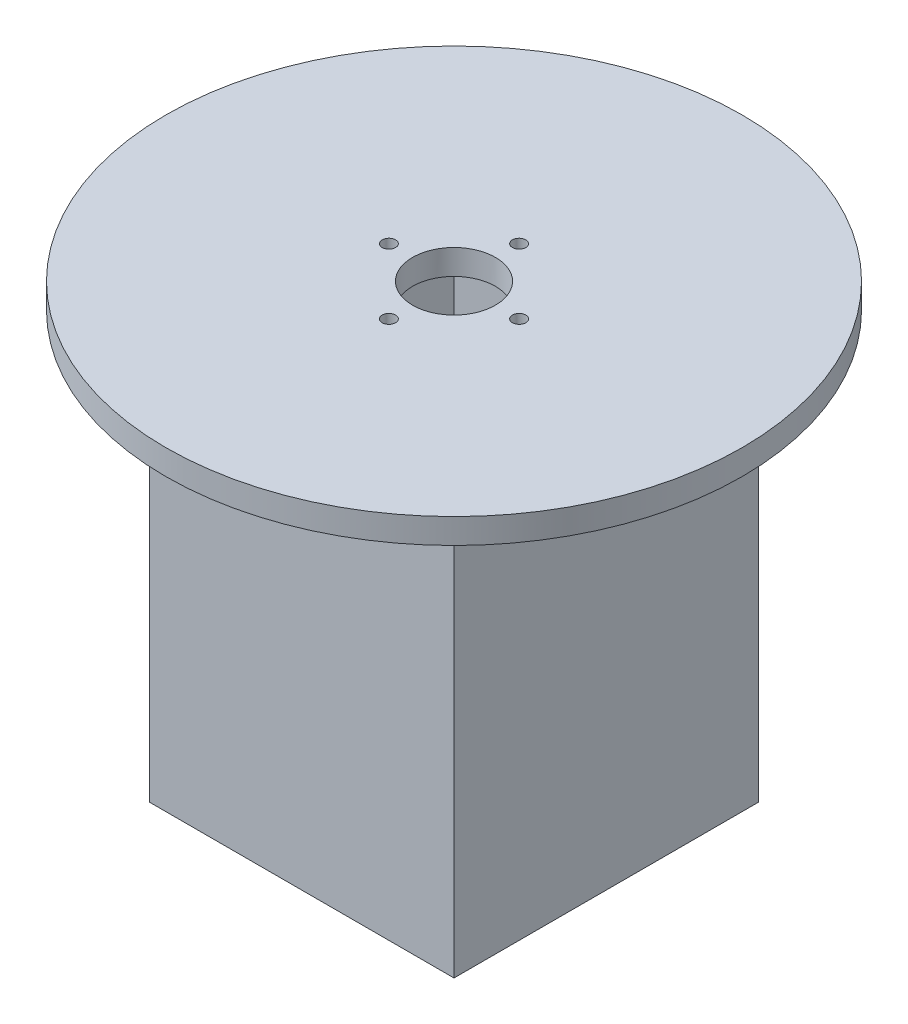
from build123d import *

# Parameters (mm, degrees)
SKETCH1_W           = 77.2
SKETCH1_H           = 114.3
BOSS_EXTRUDE1_DEPTH = 77.2
SKETCH2_W           = 70.58
SKETCH2_H           = 70.58
CUT_EXTRUDE1_DEPTH  = 107.95
SKETCH3_R           = 10.5
SKETCH3_R_2         = 1.7
CUT_EXTRUDE2_DEPTH  = 115.3
SKETCH4_R           = 73.025
SKETCH4_R_2         = 1.7
SKETCH4_R_3         = 10.5
BOSS_EXTRUDE4_DEPTH = 6.35


with BuildPart() as part:
    # Sketch1 → Boss-Extrude1 (new body)
    with BuildSketch(Plane.XY):
        with Locations((38.6, 57.15)):
            Rectangle(SKETCH1_W, SKETCH1_H)
    extrude(amount=-BOSS_EXTRUDE1_DEPTH)

    # Sketch2 → Cut-Extrude1 (cut)
    with BuildSketch(Plane.XZ):
        with Locations((38.6, -38.6)):
            Rectangle(SKETCH2_W, SKETCH2_H)
    extrude(amount=-CUT_EXTRUDE1_DEPTH, mode=Mode.SUBTRACT)

    # Sketch3 → Cut-Extrude2 (cut, through all)
    with BuildSketch(Plane(origin=(0, 114.3, 0), x_dir=(1, 0, 0), z_dir=(0, 1, 0))):
        with Locations((38.6, 38.6)):
            Circle(SKETCH3_R)
        with Locations((38.6, 55.1)):
            Circle(SKETCH3_R_2)
        with Locations((55.1, 38.6)):
            Circle(SKETCH3_R_2)
        with Locations((38.6, 22.1)):
            Circle(SKETCH3_R_2)
        with Locations((22.1, 38.6)):
            Circle(SKETCH3_R_2)
    extrude(amount=-CUT_EXTRUDE2_DEPTH, mode=Mode.SUBTRACT)

    # Sketch4 → Boss-Extrude4 (add)
    with BuildSketch(Plane(origin=(0, 114.3, 0), x_dir=(1, 0, 0), z_dir=(0, 1, 0))):
        with Locations((38.6, 38.6)):
            Circle(SKETCH4_R)
        with Locations((38.6, 55.1)):
            Circle(SKETCH4_R_2, mode=Mode.SUBTRACT)
        with Locations((55.1, 38.6)):
            Circle(SKETCH4_R_2, mode=Mode.SUBTRACT)
        with Locations((38.6, 22.1)):
            Circle(SKETCH4_R_2, mode=Mode.SUBTRACT)
        with Locations((22.1, 38.6)):
            Circle(SKETCH4_R_2, mode=Mode.SUBTRACT)
        with Locations((38.6, 38.6)):
            Circle(SKETCH4_R_3, mode=Mode.SUBTRACT)
    extrude(amount=-BOSS_EXTRUDE4_DEPTH)


solid = part.part
